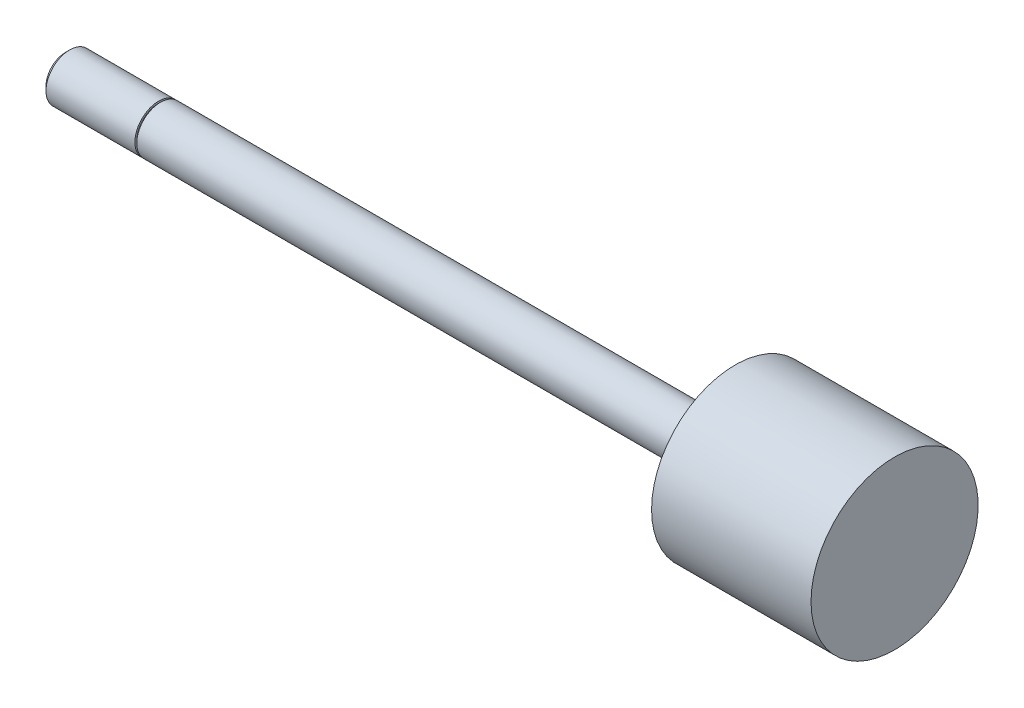
from build123d import *

# Parameters (mm, degrees)
SKETCH3_W = 0.254
SKETCH3_H = 0.508


with BuildPart() as part:
    # Sketch1 → Revolve1 (revolve)
    with BuildSketch(Plane.XY):
        Polygon((0, 0), (0, 3.175), (76.9874, 3.175), (76.9874, 11.19505), (98.3488, 11.19505), (98.3488, 0), align=None)
    revolve(axis=Axis((98.3488, 0, 0), (-1, 0, 0)))

    # Sketch2 → Revolve2 (revolve)
    with BuildSketch(Plane.XY):
        Polygon((-12.7, 0), (-12.7, 2.63398), (-12.15898, 3.175), (0, 3.175), (0, 0), align=None)
    revolve(axis=Axis((0, 0, 0), (-1, 0, 0)))

    # Sketch3 → Cut-Revolve1 (revolve, cut)
    with BuildSketch(Plane.XY):
        with Locations((-0.127, 3.175)):
            Rectangle(SKETCH3_W, SKETCH3_H)
    revolve(axis=Axis((0, 0, 0), (-1, 0, 0)), mode=Mode.SUBTRACT)


solid = part.part
